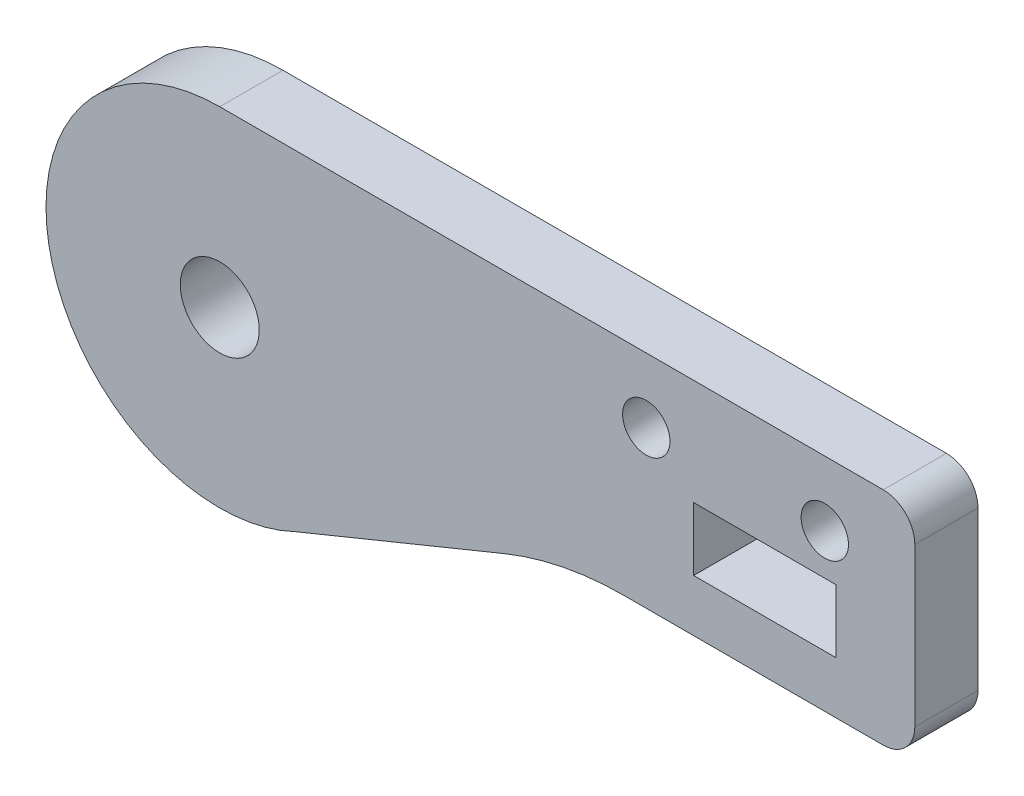
from build123d import *

# Parameters (mm, degrees)
SKETCH1_R           = 1.5
SKETCH1_R_2         = 2.5
SKETCH1_W           = 9
SKETCH1_H           = 4
BOSS_EXTRUDE1_DEPTH = 4


with BuildPart() as part:
    # Sketch1 → Boss-Extrude1 (new body)
    with BuildSketch(Plane.XY):
        with BuildLine():
            Line((55, 39.098584833), (55, 29.098584833))
            ThreePointArc((55, 29.098584833), (54.414213562, 27.684371271), (53, 27.098584833))
            Line((53, 27.098584833), (36.598884751, 27.098584833))
            ThreePointArc((36.598884751, 27.098584833), (32.740210108, 26.722820615), (29.026530651, 25.609647833))
            Line((29.026530651, 25.609647833), (15.772178259, 20.187665872))
            ThreePointArc((15.772178259, 20.187665872), (0.275725932, 27.651148274), (11, 41.098584833))
            Line((11, 41.098584833), (53, 41.098584833))
            ThreePointArc((53, 41.098584833), (54.414213562, 40.512798396), (55, 39.098584833))
        make_face()
        with Locations((38, 36.998584833)):
            Circle(SKETCH1_R, mode=Mode.SUBTRACT)
        with Locations((49.3, 36.998584833)):
            Circle(SKETCH1_R, mode=Mode.SUBTRACT)
        with Locations((11, 30.098584833)):
            Circle(SKETCH1_R_2, mode=Mode.SUBTRACT)
        with Locations((45.5, 32.398584833)):
            Rectangle(SKETCH1_W, SKETCH1_H, mode=Mode.SUBTRACT)
    extrude(amount=BOSS_EXTRUDE1_DEPTH)


solid = part.part
